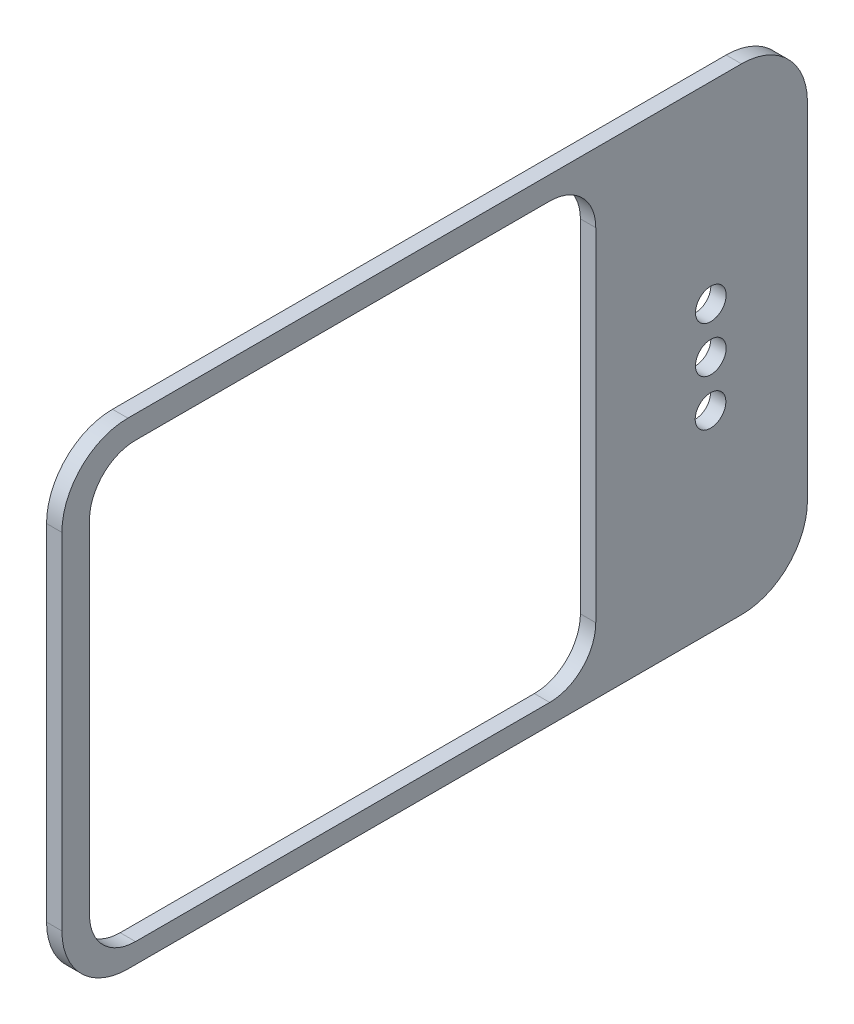
from build123d import *

# Parameters (mm, degrees)
EXTRUDE_1_DEPTH     = 1
CUT_EXTRUDE_1_DEPTH = 2
SKETCH_3_R          = 1
CUT_EXTRUDE_2_DEPTH = 2


with BuildPart() as part:
    # 草图1 → 凸台-拉伸1 (new body)
    with BuildSketch(Plane(origin=(0, 0, 0), x_dir=(0, 0, -1), z_dir=(1, 0, 0))):
        with BuildLine():
            Line((26.809806157, -1.747534601), (26.809806157, 20.752465399))
            ThreePointArc((26.809806157, 20.752465399), (25.550365316, 23.793024558), (22.509806157, 25.052465399))
            Line((22.509806157, 25.052465399), (-17.490193843, 25.052465399))
            ThreePointArc((-17.490193843, 25.052465399), (-20.530753002, 23.793024558), (-21.790193843, 20.752465399))
            Line((-21.790193843, 20.752465399), (-21.790193843, -1.747534601))
            ThreePointArc((-21.790193843, -1.747534601), (-20.530753002, -4.78809376), (-17.490193843, -6.047534601))
            Line((-17.490193843, -6.047534601), (22.509806157, -6.047534601))
            ThreePointArc((22.509806157, -6.047534601), (25.550365316, -4.78809376), (26.809806157, -1.747534601))
        make_face()
    extrude(amount=EXTRUDE_1_DEPTH)

    # 草图2 → 切除-拉伸1 (cut, through all)
    with BuildSketch(Plane.ZY):
        with BuildLine():
            Line((-13.009806157, 20.552465399), (-13.009806157, -1.747534601))
            ThreePointArc((-13.009806157, -1.747534601), (-12.131126501, -3.868854944), (-10.009806157, -4.747534601))
            Line((-10.009806157, -4.747534601), (16.990193843, -4.747534601))
            ThreePointArc((16.990193843, -4.747534601), (19.111514186, -3.868854944), (19.990193843, -1.747534601))
            Line((19.990193843, -1.747534601), (19.990193843, 20.552465399))
            ThreePointArc((19.990193843, 20.552465399), (19.111514186, 22.673785743), (16.990193843, 23.552465399))
            Line((16.990193843, 23.552465399), (-10.009806157, 23.552465399))
            ThreePointArc((-10.009806157, 23.552465399), (-12.131126501, 22.673785743), (-13.009806157, 20.552465399))
        make_face()
    extrude(amount=-CUT_EXTRUDE_1_DEPTH, mode=Mode.SUBTRACT)

    # 草图3 → 切除-拉伸2 (cut, through all)
    with BuildSketch(Plane.ZY):
        with Locations((-20.491320576, 6.494332556)):
            Circle(SKETCH_3_R)
        with Locations((-20.509806157, 9.502465399)):
            Circle(SKETCH_3_R)
        with Locations((-20.509806157, 12.502465399)):
            Circle(SKETCH_3_R)
    extrude(amount=-CUT_EXTRUDE_2_DEPTH, mode=Mode.SUBTRACT)


solid = part.part
